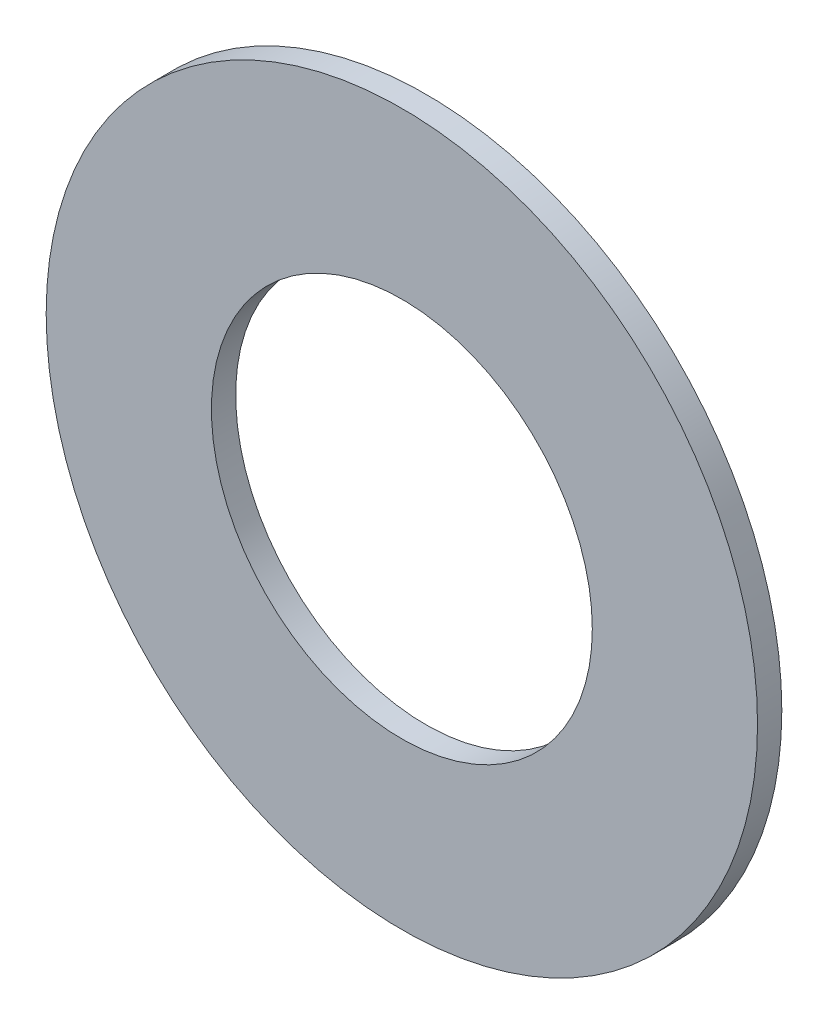
from build123d import *

# Parameters (mm, degrees)
SKETCH3_R                = 11.90625
SKETCH3_R_2              = 6.3754
BOSS_EXTRUDE1_DEPTH      = 0.4064
BOSS_EXTRUDE1_DEPTH_BACK = 0.4064


with BuildPart() as part:
    # Sketch3 → Boss-Extrude1 (new body, two sides)
    with BuildSketch(Plane.XY) as boss_extrude1_sk:
        Circle(SKETCH3_R)
        Circle(SKETCH3_R_2, mode=Mode.SUBTRACT)
    extrude(amount=BOSS_EXTRUDE1_DEPTH)
    extrude(boss_extrude1_sk.sketch, amount=-BOSS_EXTRUDE1_DEPTH_BACK)


solid = part.part
